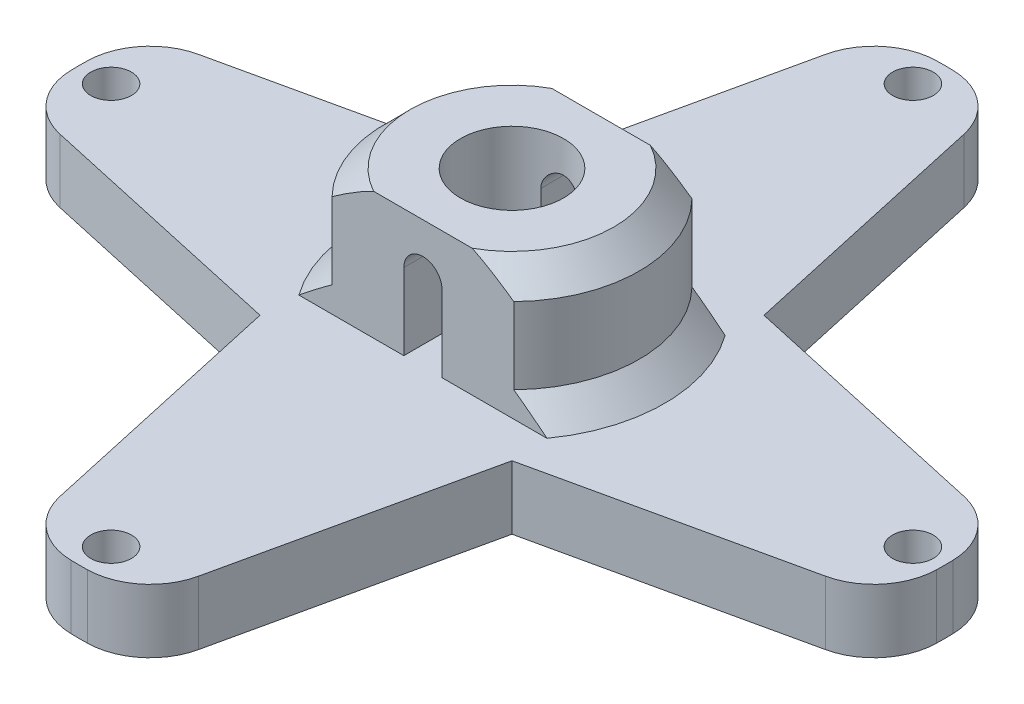
from build123d import *

# Parameters (mm, degrees)
SKETCH1_R           = 34
SKETCH1_R_2         = 1.6
SKETCH1_R_3         = 4.05
BOSS_EXTRUDE1_DEPTH = 5
SKETCH2_R           = 4.05
BOSS_EXTRUDE2_DEPTH = 10
CUT_EXTRUDE1_DEPTH  = 42
CUT_EXTRUDE2_DEPTH  = 10
FILLET1_R           = 5
CHAMFER2_SIZE       = 2


with BuildPart() as part:
    # Sketch1 → Boss-Extrude1 (new body)
    with BuildSketch(Plane(origin=(0, 0, 0), x_dir=(1, 0, 0), z_dir=(0, 1, 0))):
        Circle(SKETCH1_R)
        with Locations((0, 31.5)):
            Circle(SKETCH1_R_2, mode=Mode.SUBTRACT)
        with Locations((31.5, 0)):
            Circle(SKETCH1_R_2, mode=Mode.SUBTRACT)
        with Locations((0, -31.5)):
            Circle(SKETCH1_R_2, mode=Mode.SUBTRACT)
        with Locations((-31.5, 0)):
            Circle(SKETCH1_R_2, mode=Mode.SUBTRACT)
        Circle(SKETCH1_R_3, mode=Mode.SUBTRACT)
    extrude(amount=BOSS_EXTRUDE1_DEPTH)

    # Sketch2 → Boss-Extrude2 (add)
    with BuildSketch(Plane(origin=(0, 5, 0), x_dir=(1, 0, 0), z_dir=(0, 1, 0))):
        with BuildLine():
            Line((-7.141428429, 7), (7.141428429, 7))
            ThreePointArc((7.141428429, 7), (10, 0), (7.141428429, -7))
            Line((7.141428429, -7), (-7.141428429, -7))
            ThreePointArc((-7.141428429, -7), (-10, 0), (-7.141428429, 7))
        make_face()
        Circle(SKETCH2_R, mode=Mode.SUBTRACT)
    extrude(amount=BOSS_EXTRUDE2_DEPTH)

    # Sketch3 → Cut-Extrude1 (cut, through all)
    with BuildSketch(Plane(origin=(0, 0, -7), x_dir=(-1, 0, 0), z_dir=(0, 0, -1))):
        with BuildLine():
            Line((1.5, 5), (1.5, 11))
            ThreePointArc((1.5, 11), (0, 12.5), (-1.5, 11))
            Line((-1.5, 11), (-1.5, 5))
            Line((-1.5, 5), (1.5, 5))
        make_face()
    extrude(amount=-CUT_EXTRUDE1_DEPTH, mode=Mode.SUBTRACT)

    # Sketch4 → Cut-Extrude2 (cut)
    with BuildSketch(Plane(origin=(0, 5, 0), x_dir=(1, 0, 0), z_dir=(0, 1, 0))):
        with BuildLine():
            Line((-33.682156271, 4.638140673), (-9.899494937, 9.899494937))
            Line((-9.899494937, 9.899494937), (-4.638140673, 33.682156271))
            ThreePointArc((-4.638140673, 33.682156271), (-24.04163056, 24.04163056), (-33.682156271, 4.638140673))
        make_face()
        with BuildLine():
            Line((4.638140673, 33.682156271), (9.899494937, 9.899494937))
            Line((9.899494937, 9.899494937), (33.682156271, 4.638140673))
            ThreePointArc((33.682156271, 4.638140673), (24.04163056, 24.04163056), (4.638140673, 33.682156271))
        make_face()
        with BuildLine():
            Line((33.682156271, -4.638140673), (9.899494937, -9.899494937))
            Line((9.899494937, -9.899494937), (4.638140673, -33.682156271))
            ThreePointArc((4.638140673, -33.682156271), (24.04163056, -24.04163056), (33.682156271, -4.638140673))
        make_face()
        with BuildLine():
            Line((-4.638140673, -33.682156271), (-9.899494937, -9.899494937))
            Line((-9.899494937, -9.899494937), (-33.682156271, -4.638140673))
            ThreePointArc((-33.682156271, -4.638140673), (-24.04163056, -24.04163056), (-4.638140673, -33.682156271))
        make_face()
    extrude(amount=-CUT_EXTRUDE2_DEPTH, mode=Mode.SUBTRACT)

    # Fillet1
    fillet1_edges = [part.edges().sort_by_distance(p)[0] for p in [
        (-9.899494937, 2.5, -9.899494937),
        (-33.682156271, 2.5, -4.638140673),
        (-4.638140673, 2.5, -33.682156271),
        (4.638140673, 2.5, -33.682156271),
        (33.682156271, 2.5, -4.638140673),
        (33.682156271, 2.5, 4.638140673),
        (4.638140673, 2.5, 33.682156271),
        (-4.638140673, 2.5, 33.682156271),
        (-33.682156271, 2.5, 4.638140673),
    ]]
    fillet(fillet1_edges, radius=FILLET1_R)

    # Chamfer2
    chamfer2_edges = [part.edges().sort_by_distance(p)[0] for p in [
        (-10, 15, 0),
        (10, 15, 0),
        (-10, 5, 0),
        (10, 5, 0),
    ]]
    chamfer(chamfer2_edges, length=CHAMFER2_SIZE)


solid = part.part
